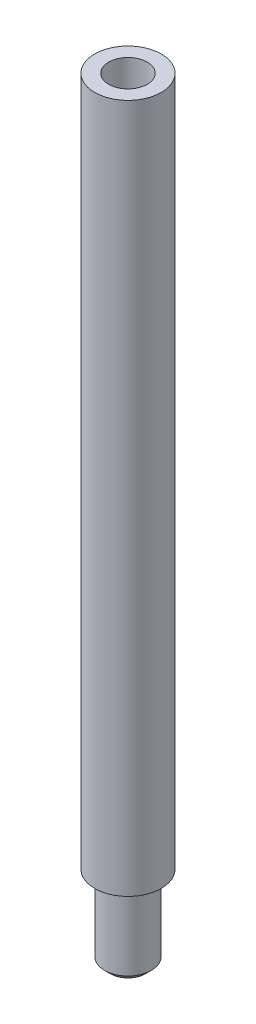
from build123d import *

# Parameters (mm, degrees)
SKETCH1_R                 = 2.85
BOSS_EXTRUDE1_DEPTH       = 59
SKETCH1_4_R               = 2
BOSS_EXTRUDE2_DEPTH       = 7
M4X0_7_TAPPED_HOLE1_D     = 3.3
M4X0_7_TAPPED_HOLE1_DEPTH = 10.1
M4X0_7_TAPPED_HOLE1_TIP   = 0.991420021
CHAMFER1_SIZE             = 0.5


with BuildPart() as part:
    # Sketch1 → Boss-Extrude1 (new body)
    with BuildSketch(Plane(origin=(0, 0, 0), x_dir=(1, 0, 0), z_dir=(0, 1, 0))):
        Circle(SKETCH1_R)
    extrude(amount=BOSS_EXTRUDE1_DEPTH)

    # Sketch1_4 → Boss-Extrude2 (add)
    with BuildSketch(Plane(origin=(0, 0, 0), x_dir=(1, 0, 0), z_dir=(0, 1, 0))):
        Circle(SKETCH1_4_R)
    extrude(amount=-BOSS_EXTRUDE2_DEPTH)

    # M4x0.7 Tapped Hole1
    with Locations(Plane(origin=(0, 59, 0), x_dir=(1, 0, 0), z_dir=(0, 1, 0))):
        with Locations((0, 0)):
            Hole(M4X0_7_TAPPED_HOLE1_D / 2, depth=M4X0_7_TAPPED_HOLE1_DEPTH)
            with Locations((0, 0, -(M4X0_7_TAPPED_HOLE1_DEPTH + M4X0_7_TAPPED_HOLE1_TIP / 2))):  # 118° drill point
                Cone(0, M4X0_7_TAPPED_HOLE1_D / 2, M4X0_7_TAPPED_HOLE1_TIP, mode=Mode.SUBTRACT)

    # Chamfer1
    chamfer1_edges = [part.edges().sort_by_distance(p)[0] for p in [
        (-2, -7, 0),
    ]]
    chamfer(chamfer1_edges, length=CHAMFER1_SIZE)


solid = part.part
